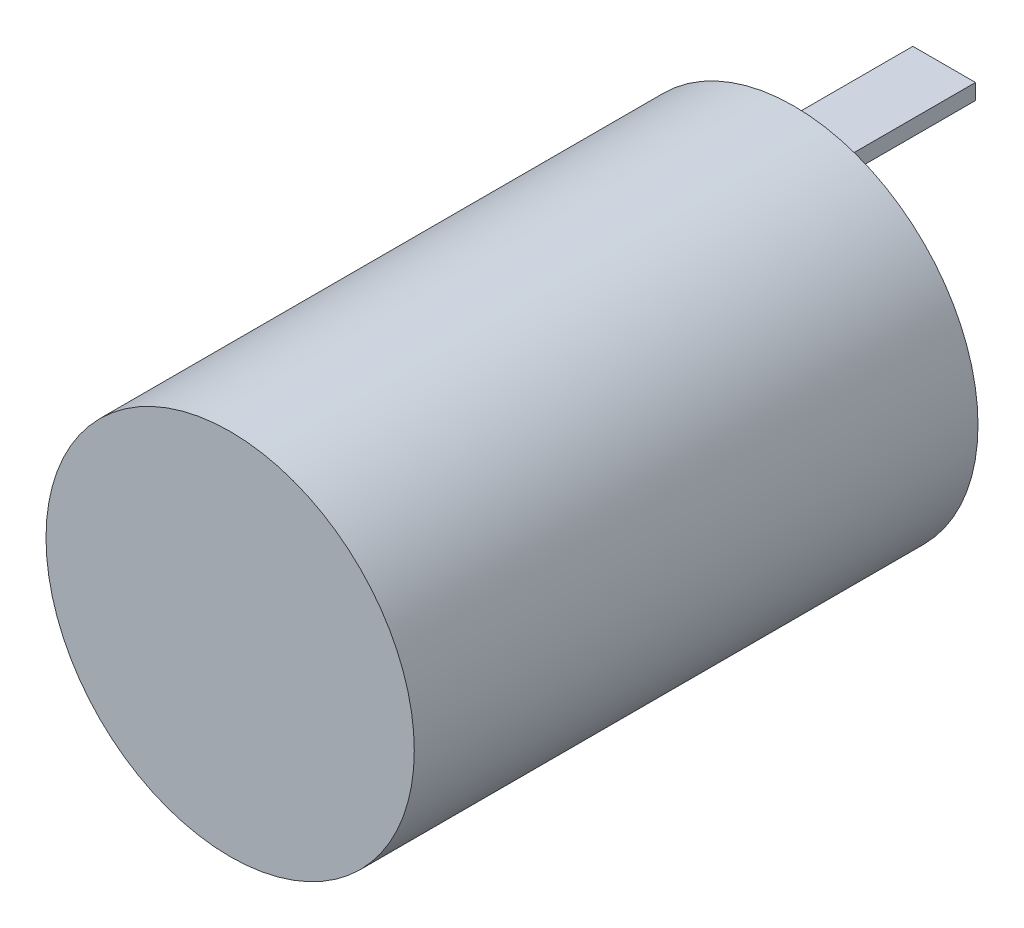
from build123d import *

# Parameters (mm, degrees)
SKETCH1_R           = 18.669
BOSS_EXTRUDE1_DEPTH = 57.15
SKETCH2_W           = 6.35
SKETCH2_H           = 1.5875
BOSS_EXTRUDE2_DEPTH = 15.24


with BuildPart() as part:
    # Sketch1 → Boss-Extrude1 (new body)
    with BuildSketch(Plane.XY):
        Circle(SKETCH1_R)
    extrude(amount=BOSS_EXTRUDE1_DEPTH)

    # Sketch2 → Boss-Extrude2 (add)
    with BuildSketch(Plane(origin=(0, 0, 0), x_dir=(-1, 0, 0), z_dir=(0, 0, -1))):
        with Locations((0, 13.9065)):
            Rectangle(SKETCH2_W, SKETCH2_H)
        with Locations((0, -13.9065)):
            Rectangle(SKETCH2_W, SKETCH2_H)
    extrude(amount=BOSS_EXTRUDE2_DEPTH)


solid = part.part
